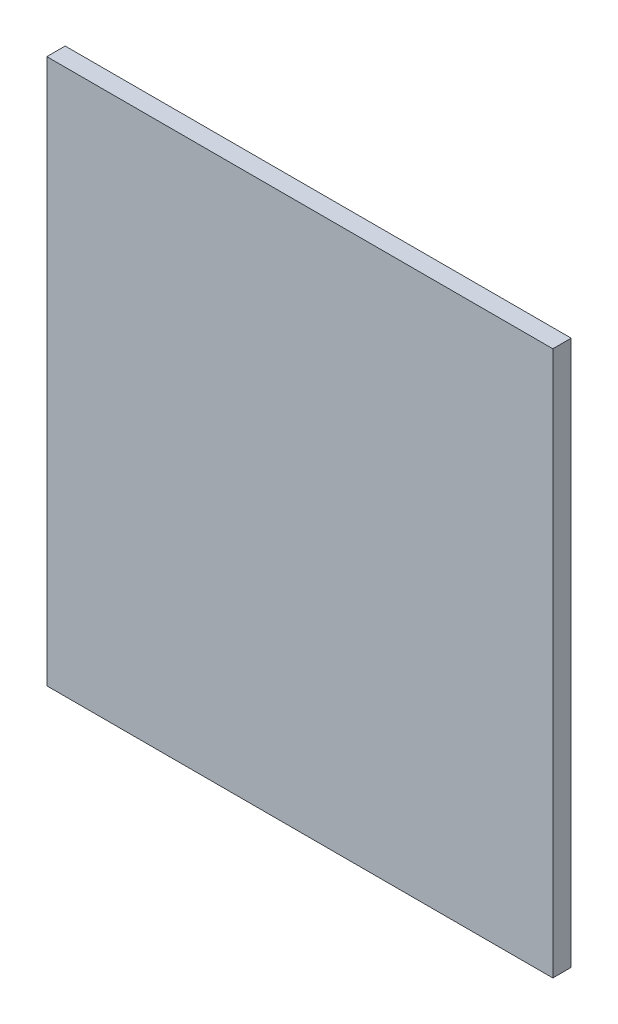
from build123d import *

# Parameters (mm, degrees)
SKETCH1_W           = 82.55
SKETCH1_H           = 88.9
BOSS_EXTRUDE2_DEPTH = 2.9972


with BuildPart() as part:
    # Sketch1 → Boss-Extrude2 (new body)
    with BuildSketch(Plane.XY):
        with Locations((41.275, -44.45)):
            Rectangle(SKETCH1_W, SKETCH1_H)
    extrude(amount=BOSS_EXTRUDE2_DEPTH)


solid = part.part
